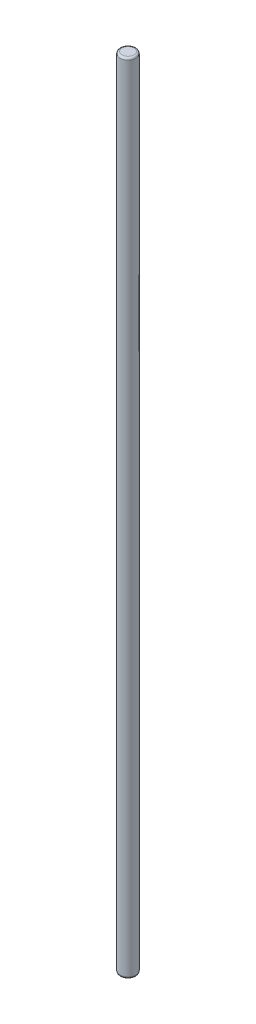
from build123d import *

# Parameters (mm, degrees)
SKETCH1_R           = 4
BOSS_EXTRUDE1_DEPTH = 400
FILLET2_R           = 1


with BuildPart() as part:
    # Sketch1 → Boss-Extrude1 (new body)
    with BuildSketch(Plane(origin=(0, 0, 0), x_dir=(1, 0, 0), z_dir=(0, 1, 0))):
        Circle(SKETCH1_R)
    extrude(amount=BOSS_EXTRUDE1_DEPTH)

    # Fillet2
    fillet2_edges = [part.edges().sort_by_distance(p)[0] for p in [
        (-4, 0, 0),
        (-4, 400, 0),
    ]]
    fillet(fillet2_edges, radius=FILLET2_R)


solid = part.part
